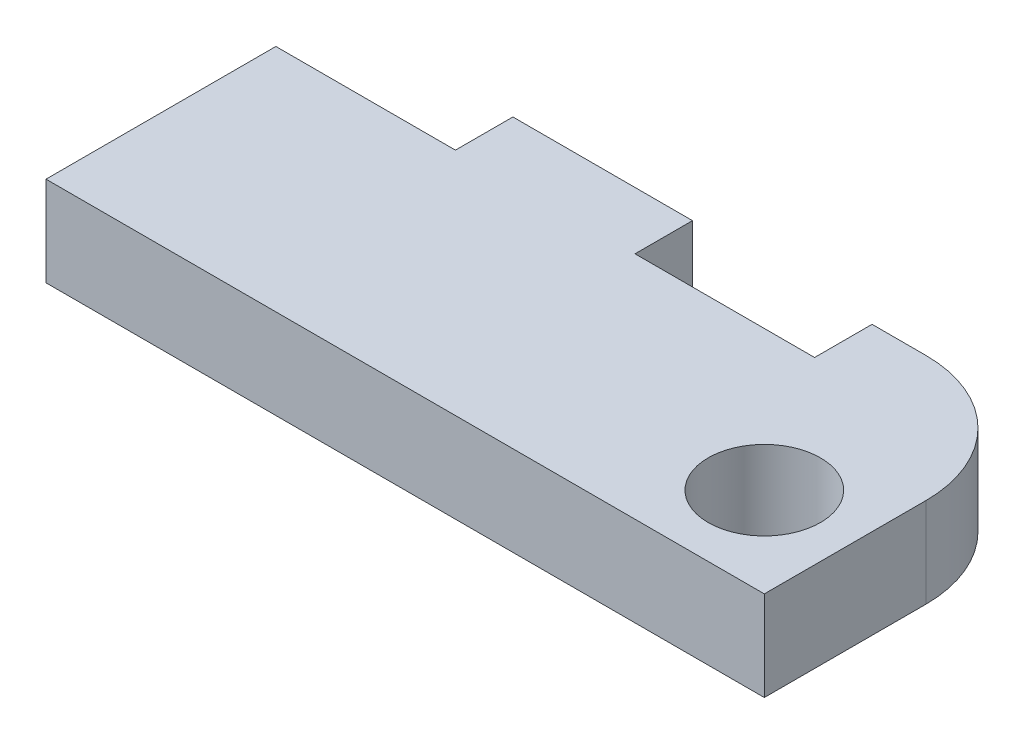
from build123d import *

# Parameters (mm, degrees)
ESQUISSE1_W                = 40
ESQUISSE1_H                = 5
BOSS_EXTRU_1_DEPTH         = 10
ESQUISSE2_R                = 3.125
ENL_V_MAT_EXTRU_1_DEPTH    = 6
ESQUISSE3_W                = 40
ESQUISSE3_H                = 5
BOSS_EXTRU_2_DEPTH         = 6
CONG_1_R                   = 7
ESQUISSE5_W                = 10
ESQUISSE5_H                = 5
ENL_V_MAT_EXTRU_3_DEPTH    = 3.2
R_P_TITION_LIN_AIRE1_COUNT = 2
R_P_TITION_LIN_AIRE1_PITCH = 20


with BuildPart() as part:
    # Esquisse1 → Boss.-Extru.1 (new body)
    with BuildSketch(Plane.XY):
        with Locations((20, -2.5)):
            Rectangle(ESQUISSE1_W, ESQUISSE1_H)
    extrude(amount=BOSS_EXTRU_1_DEPTH)

    # Esquisse2 → Enlèv. mat.-Extru.1 (cut, through all)
    with BuildSketch(Plane(origin=(0, 0, 0), x_dir=(1, 0, 0), z_dir=(0, 1, 0))):
        with Locations((35, -5)):
            Circle(ESQUISSE2_R)
    extrude(amount=-ENL_V_MAT_EXTRU_1_DEPTH, mode=Mode.SUBTRACT)

    # Esquisse3 → Boss.-Extru.2 (add)
    with BuildSketch(Plane(origin=(0, 0, 0), x_dir=(-1, 0, 0), z_dir=(0, 0, -1))):
        with Locations((-20, -2.5)):
            Rectangle(ESQUISSE3_W, ESQUISSE3_H)
    extrude(amount=BOSS_EXTRU_2_DEPTH)

    # Congé1
    cong_1_edges = [part.edges().sort_by_distance(p)[0] for p in [
        (40, -2.5, -6),
    ]]
    fillet(cong_1_edges, radius=CONG_1_R)

    # Esquisse5 → Enlèv. mat.-Extru.3 (cut)
    with BuildSketch(Plane(origin=(0, 0, -6), x_dir=(-1, 0, 0), z_dir=(0, 0, -1))):
        with Locations((-5, -2.5)):
            Rectangle(ESQUISSE5_W, ESQUISSE5_H)
    enl_v_mat_extru_3 = extrude(amount=-ENL_V_MAT_EXTRU_3_DEPTH, mode=Mode.SUBTRACT)

    # Répétition linéaire1: Enlèv. mat.-Extru.3 ×2
    with Locations(*[(i * R_P_TITION_LIN_AIRE1_PITCH, 0, 0) for i in range(1, R_P_TITION_LIN_AIRE1_COUNT)]):
        add(enl_v_mat_extru_3, mode=Mode.SUBTRACT)


solid = part.part
